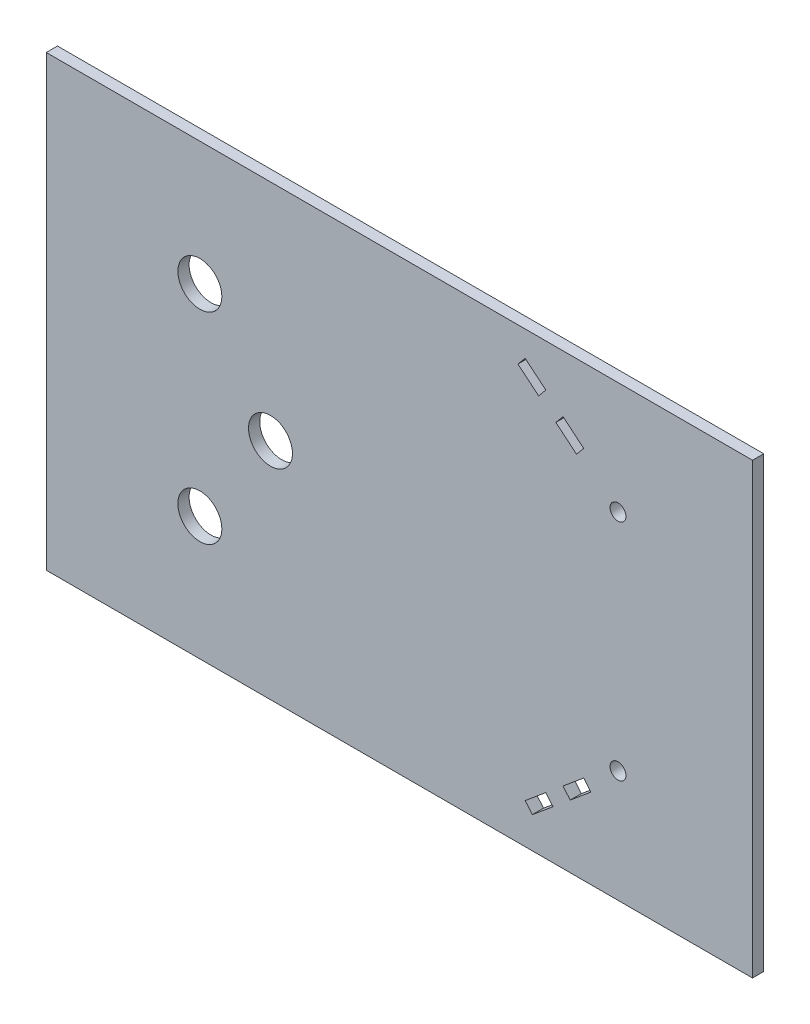
from build123d import *

# Parameters (mm, degrees)
SKETCH1_W           = 400.05
SKETCH1_H           = 254
BOSS_EXTRUDE1_DEPTH = 6.35
SKETCH2_R           = 4.5
SKETCH2_R_2         = 12.446
CUT_EXTRUDE1_DEPTH  = 6.35


with BuildPart() as part:
    # Sketch1 → Boss-Extrude1 (new body)
    with BuildSketch(Plane.XY):
        with Locations((200.025, 127)):
            Rectangle(SKETCH1_W, SKETCH1_H)
    extrude(amount=BOSS_EXTRUDE1_DEPTH)

    # Sketch2 → Cut-Extrude1 (cut)
    with BuildSketch(Plane.XY.offset(6.35)):
        with Locations((323.85, 63.5)):
            Circle(SKETCH2_R)
        with Locations((323.85, 190.5)):
            Circle(SKETCH2_R)
        with Locations((127, 127)):
            Circle(SKETCH2_R_2)
        with Locations((87, 70)):
            Circle(SKETCH2_R_2)
        with Locations((87, 184)):
            Circle(SKETCH2_R_2)
        Polygon((275.320145198, 17.766787665), (287.027837499, 27.523197916), (282.962666561, 32.401403041), (271.25497426, 22.64499279), align=None)
        Polygon((296.78424775, 35.653539792), (308.491940051, 45.409950042), (304.426769113, 50.288155168), (292.719076812, 40.531744917), align=None)
        Polygon((271.25497426, 239.620854783), (282.962666561, 229.864444532), (278.897495623, 224.986239407), (267.189803322, 234.742649658), align=None)
        Polygon((292.719076812, 221.734102657), (304.426769113, 211.977692406), (300.361598175, 207.09948728), (288.653905874, 216.855897531), align=None)
    extrude(amount=-CUT_EXTRUDE1_DEPTH, mode=Mode.SUBTRACT)


solid = part.part
